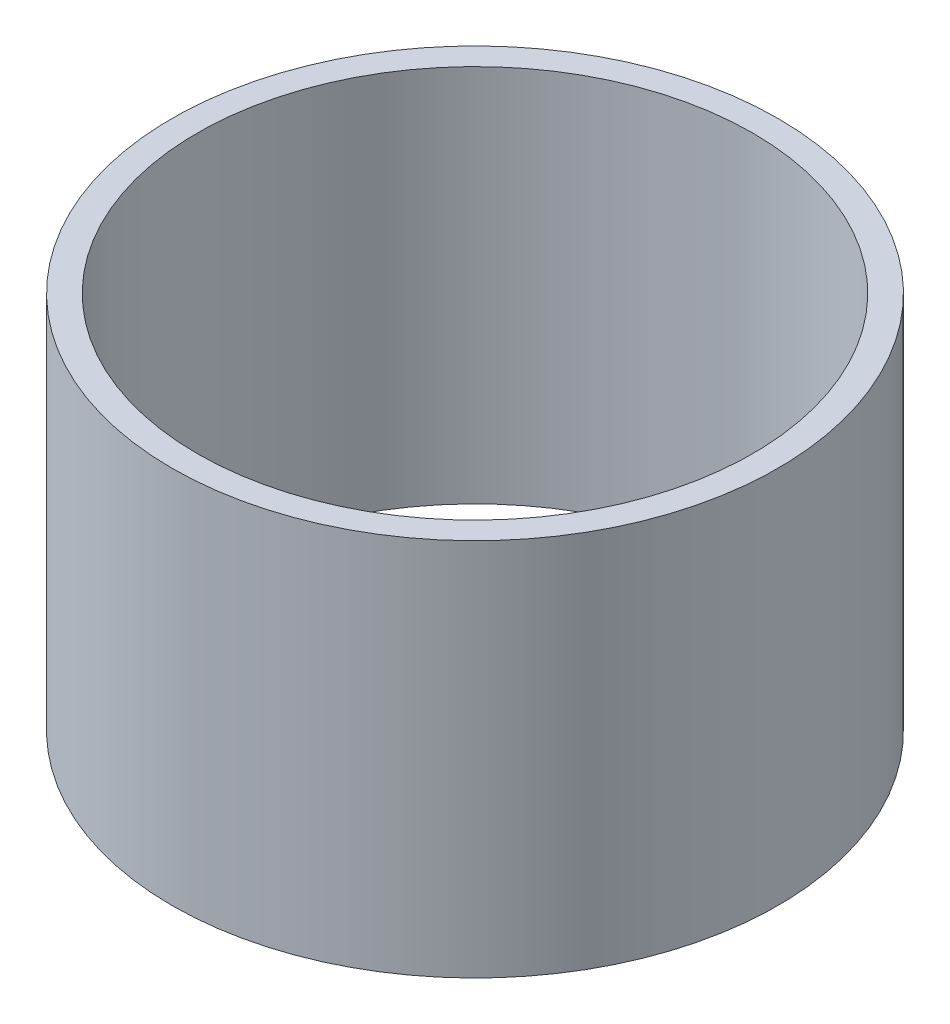
from build123d import *

# Parameters (mm, degrees)
SKETCH_1_R      = 6
SKETCH_1_R_2    = 5.5
EXTRUDE_1_DEPTH = 7.5


with BuildPart() as part:
    # 草图1 → 凸台-拉伸1 (new body)
    with BuildSketch(Plane(origin=(0, 0, 0), x_dir=(1, 0, 0), z_dir=(0, 1, 0))):
        Circle(SKETCH_1_R)
        Circle(SKETCH_1_R_2, mode=Mode.SUBTRACT)
    extrude(amount=EXTRUDE_1_DEPTH)


solid = part.part
